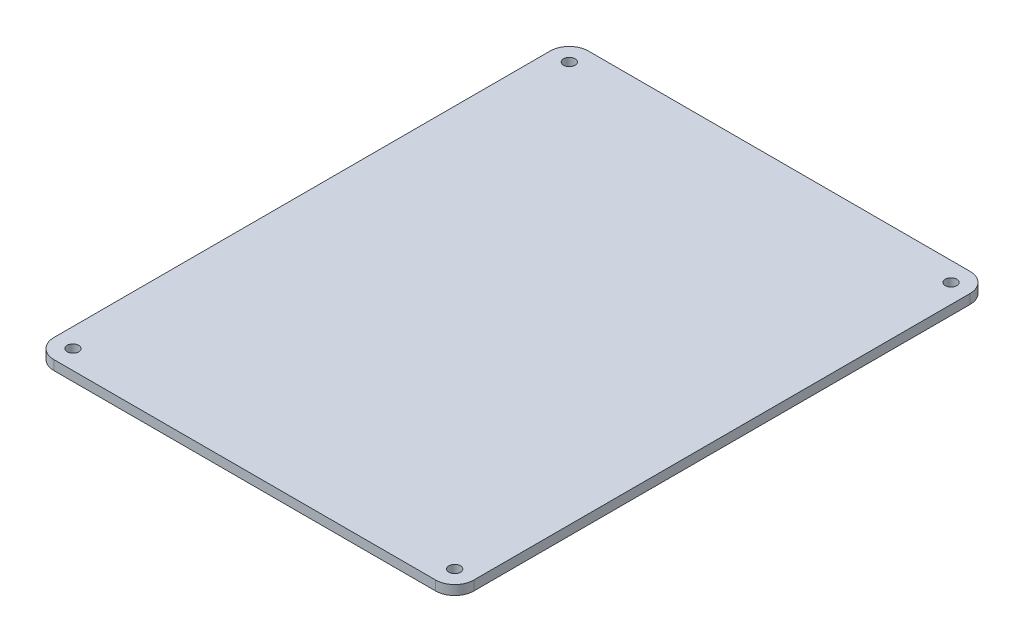
from build123d import *

# Parameters (mm, degrees)
SKETCH_1_R      = 1.5
EXTRUDE_1_DEPTH = 2.5


with BuildPart() as part:
    # 草图1 → 凸台-拉伸1 (new body)
    with BuildSketch(Plane(origin=(0, 177.13711373, 0), x_dir=(1, 0, 0), z_dir=(0, 1, 0))):
        with BuildLine():
            Line((-133.099479225, -1.727321584), (-33.099479225, -1.727321584))
            ThreePointArc((-33.099479225, -1.727321584), (-29.563945319, -3.191787678), (-28.099479225, -6.727321584))
            Line((-28.099479225, -6.727321584), (-28.099479225, -136.727321584))
            ThreePointArc((-28.099479225, -136.727321584), (-29.563945319, -140.26285549), (-33.099479225, -141.727321584))
            Line((-33.099479225, -141.727321584), (-133.099479225, -141.727321584))
            ThreePointArc((-133.099479225, -141.727321584), (-136.635013131, -140.26285549), (-138.099479225, -136.727321584))
            Line((-138.099479225, -136.727321584), (-138.099479225, -6.727321584))
            ThreePointArc((-138.099479225, -6.727321584), (-136.635013131, -3.191787678), (-133.099479225, -1.727321584))
        make_face()
        with Locations((-133.099479225, -6.727321584)):
            Circle(SKETCH_1_R, mode=Mode.SUBTRACT)
        with Locations((-33.099479225, -6.727321584)):
            Circle(SKETCH_1_R, mode=Mode.SUBTRACT)
        with Locations((-33.099479225, -136.727321584)):
            Circle(SKETCH_1_R, mode=Mode.SUBTRACT)
        with Locations((-133.099479225, -136.727321584)):
            Circle(SKETCH_1_R, mode=Mode.SUBTRACT)
    extrude(amount=EXTRUDE_1_DEPTH)


solid = part.part
